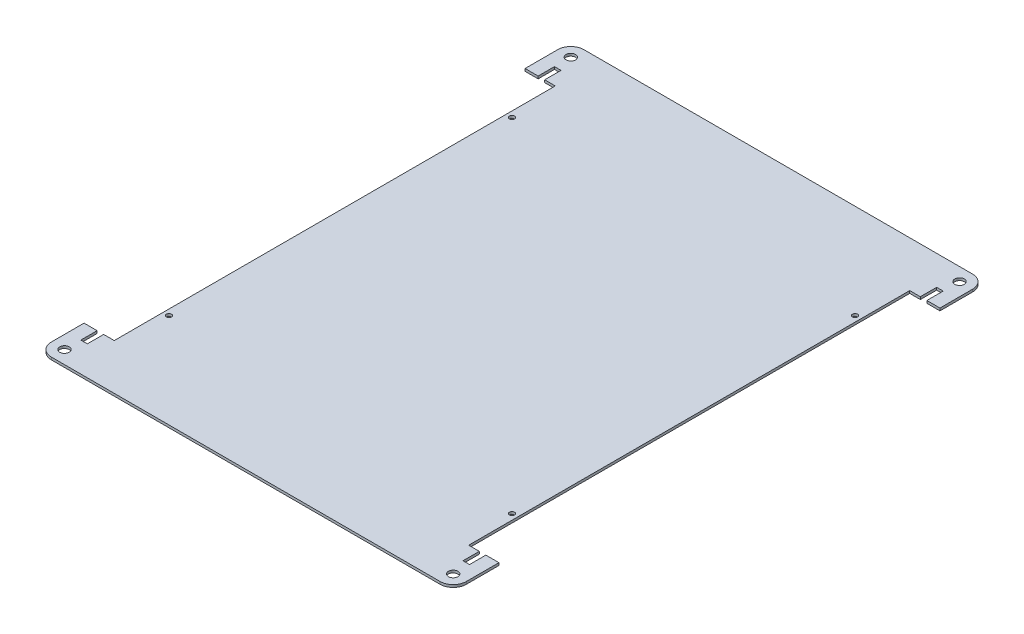
from build123d import *

# Parameters (mm, degrees)
SKETCH1_W                  = 254
SKETCH1_H                  = 326
BOSS_EXTRUDE1_DEPTH        = 1.51892
M2_5_CLEARANCE_HOLE1_D     = 3.1
M2_5_CLEARANCE_HOLE1_DEPTH = 11.938
M2_5_CLEARANCE_HOLE1_TIP   = 0.931333959
M5_CLEARANCE_HOLE1_D       = 5.8
M5_CLEARANCE_HOLE1_DEPTH   = 11.938
M5_CLEARANCE_HOLE1_TIP     = 1.742495795
FILLET1_R                  = 8
SKETCH6_W                  = 4
SKETCH6_H                  = 10
CUT_EXTRUDE1_DEPTH         = 10


with BuildPart() as part:
    # Sketch1 → Boss-Extrude1 (new body)
    with BuildSketch(Plane(origin=(0, 0, 0), x_dir=(1, 0, 0), z_dir=(0, 1, 0))):
        Rectangle(SKETCH1_W, SKETCH1_H)
    extrude(amount=BOSS_EXTRUDE1_DEPTH)

    # M2.5 Clearance Hole1
    with Locations(Plane(origin=(-105, 1.51892, 105), x_dir=(0, 0, 1), z_dir=(0, 1, 0))):
        with Locations((0, 0), (-210, 0), (-210, 210), (0, 210)):
            Hole(M2_5_CLEARANCE_HOLE1_D / 2, depth=M2_5_CLEARANCE_HOLE1_DEPTH)
            with Locations((0, 0, -(M2_5_CLEARANCE_HOLE1_DEPTH + M2_5_CLEARANCE_HOLE1_TIP / 2))):  # 118° drill point
                Cone(0, M2_5_CLEARANCE_HOLE1_D / 2, M2_5_CLEARANCE_HOLE1_TIP, mode=Mode.SUBTRACT)

    # M5 Clearance Hole1
    with Locations(Plane(origin=(0, 1.51892, 0), x_dir=(1, 0, 0), z_dir=(0, 1, 0))):
        with Locations((-119, 155), (119, 155), (119, -155), (-119, -155)):
            Hole(M5_CLEARANCE_HOLE1_D / 2, depth=M5_CLEARANCE_HOLE1_DEPTH)
            with Locations((0, 0, -(M5_CLEARANCE_HOLE1_DEPTH + M5_CLEARANCE_HOLE1_TIP / 2))):  # 118° drill point
                Cone(0, M5_CLEARANCE_HOLE1_D / 2, M5_CLEARANCE_HOLE1_TIP, mode=Mode.SUBTRACT)

    # Fillet1
    fillet1_edges = [part.edges().sort_by_distance(p)[0] for p in [
        (-127, 0.75946, -163),
        (127, 0.75946, -163),
        (127, 0.75946, 163),
        (-127, 0.75946, 163),
    ]]
    fillet(fillet1_edges, radius=FILLET1_R)

    # Sketch6 → Cut-Extrude1 (cut)
    with BuildSketch(Plane(origin=(0, 1.51892, 0), x_dir=(1, 0, 0), z_dir=(0, 1, 0))):
        Polygon((127, -135), (127, 135), (119, 135), (115, 135), (108.5, 135), (108.5, -135), (115, -135), (119, -135), align=None)
        with Locations((117, -140)):
            Rectangle(SKETCH6_W, SKETCH6_H)
        with Locations((117, 140)):
            Rectangle(SKETCH6_W, SKETCH6_H)
        Polygon((-119, -135), (-115, -135), (-108.5, -135), (-108.5, 135), (-115, 135), (-119, 135), (-127, 135), (-127, -135), align=None)
        with Locations((-117, -140)):
            Rectangle(SKETCH6_W, SKETCH6_H)
        with Locations((-117, 140)):
            Rectangle(SKETCH6_W, SKETCH6_H)
    extrude(amount=-CUT_EXTRUDE1_DEPTH, mode=Mode.SUBTRACT)


solid = part.part
